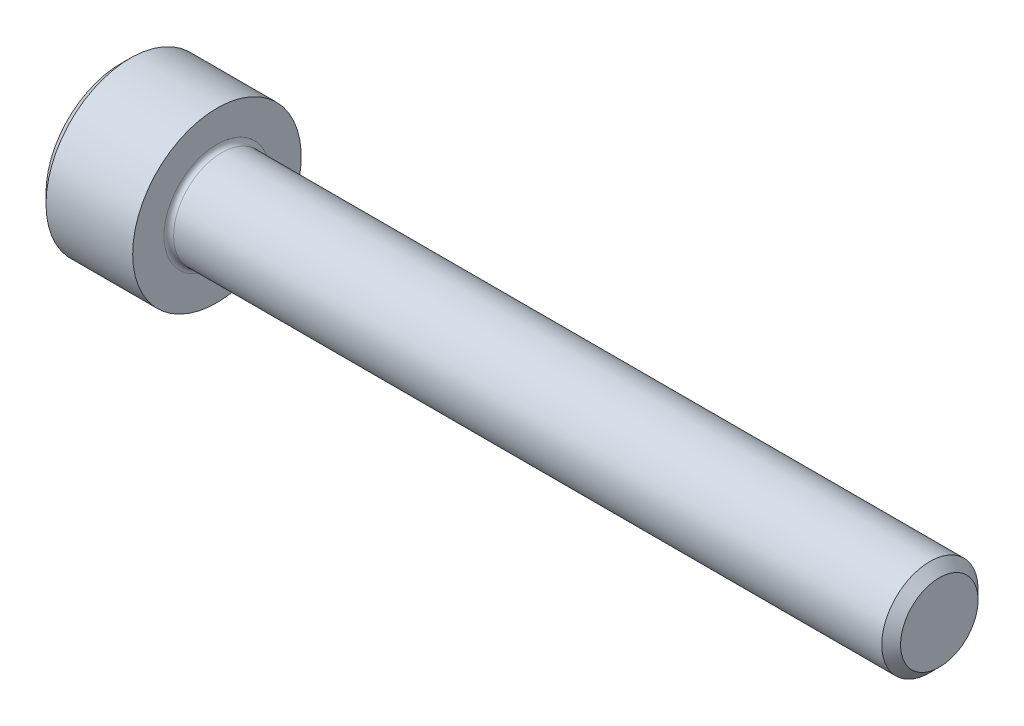
from build123d import *

# Parameters (mm, degrees)
FILLET1_R   = 0.2
HEX_2_DEPTH = 2


with BuildPart() as part:
    # BodySke → Base-Revolve (revolve)
    with BuildSketch(Plane.XY):
        Polygon((0, 0), (0, 3.1), (0.4, 3.5), (4, 3.5), (4, 2), (33.61, 2), (34, 1.61), (34, 0), align=None)
    revolve(axis=Axis((-31.75, 0, 0), (1, 0, 0)))

    # Fillet1
    fillet1_edges = [part.edges().sort_by_distance(p)[0] for p in [
        (4, -2, 0),
    ]]
    fillet(fillet1_edges, radius=FILLET1_R)

    # Sketch2 → Hex-PreBroach (revolve, cut)
    with BuildSketch(Plane.XY):
        Polygon((0, 1.5355), (2, 1.5355), (2.886521338, 0), (0, 0), align=None)
    revolve(axis=Axis((0, 0, 0), (1, 0, 0)), mode=Mode.SUBTRACT)

    # Sketch3 → Hex 2 (cut)
    with BuildSketch(Plane(origin=(0, 0, 0), x_dir=(0, 0.5, 0.866025404), z_dir=(-1, 0, 0))):
        Polygon((0.886521338, 1.5355), (-0.886521338, 1.5355), (-1.773042677, 0), (-0.886521338, -1.5355), (0.886521338, -1.5355), (1.773042677, 0), align=None)
    extrude(amount=-HEX_2_DEPTH, mode=Mode.SUBTRACT)


solid = part.part
